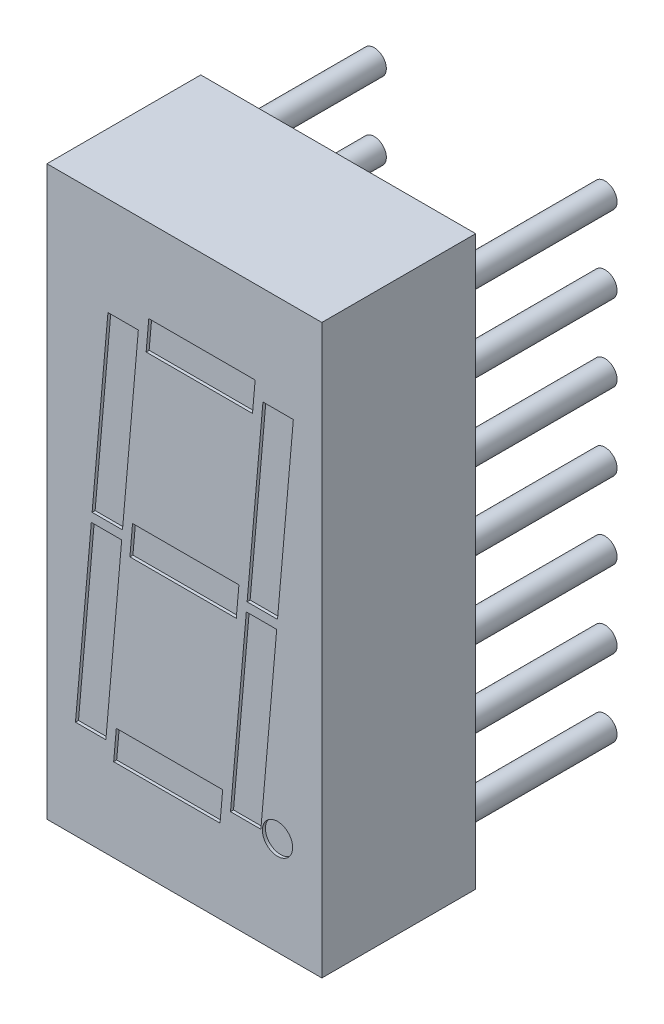
from build123d import *

# Parameters (mm, degrees)
SKETCH1_W           = 9.08
SKETCH1_H           = 18.75
BODY_DEPTH          = 5.08
SKETCH2_R           = 0.4
PINS_DEPTH          = 5
PIN_PATTERN_1_COUNT = 4
PIN_PATTERN_1_PITCH = 2.54
PIN_PATTERN_2_COUNT = 4
PIN_PATTERN_2_PITCH = 2.54
SKETCH3_R           = 0.5
LED_DISPLAY_DEPTH   = 0.1


with BuildPart() as part:
    # Sketch1 → Body (new body)
    with BuildSketch(Plane.XY):
        Rectangle(SKETCH1_W, SKETCH1_H)
    extrude(amount=BODY_DEPTH)

    # Sketch2 → Pins (add)
    with BuildSketch(Plane(origin=(0, 0, 0), x_dir=(-1, 0, 0), z_dir=(0, 0, -1))):
        with Locations((-3.81, 0)):
            Circle(SKETCH2_R)
        with Locations((3.81, 0)):
            Circle(SKETCH2_R)
    pins = extrude(amount=PINS_DEPTH)

    # Pin Pattern 1: Pins ×4
    with Locations(*[(0, -i * PIN_PATTERN_1_PITCH, 0) for i in range(1, PIN_PATTERN_1_COUNT)]):
        add(pins)

    # Pin Pattern 2: Pins ×4
    with Locations(*[(0, i * PIN_PATTERN_2_PITCH, 0) for i in range(1, PIN_PATTERN_2_COUNT)]):
        add(pins)

    # Sketch3 → LED Display (cut)
    with BuildSketch(Plane.XY.offset(5.08)):
        with Locations((3.074773804, -6.127168189)):
            Circle(SKETCH3_R)
        Polygon((-1.521772911, 6.127168189), (-2.044707367, 0.15), (-3.048527205, 0.15), (-2.525592748, 6.127168189), align=None)
        Polygon((-3.597708261, -6.127168189), (-2.593888423, -6.127168189), (-2.070953966, -0.15), (-3.074773804, -0.15), align=None)
        Polygon((2.593888423, 6.127168189), (2.070953966, 0.15), (3.074773804, 0.15), (3.597708261, 6.127168189), align=None)
        Polygon((1.521772911, -6.127168189), (2.525592748, -6.127168189), (3.048527205, -0.15), (2.044707367, -0.15), align=None)
        Polygon((-1.712940384, 0.5), (-1.800429047, -0.5), (1.712940384, -0.5), (1.800429047, 0.5), align=None)
        Polygon((-1.264371291, 5.627168189), (-1.176882628, 6.627168189), (2.336486803, 6.627168189), (2.24899814, 5.627168189), align=None)
        Polygon((-2.24899814, -5.627168189), (-2.336486803, -6.627168189), (1.176882628, -6.627168189), (1.264371291, -5.627168189), align=None)
    extrude(amount=-LED_DISPLAY_DEPTH, mode=Mode.SUBTRACT)


solid = part.part
